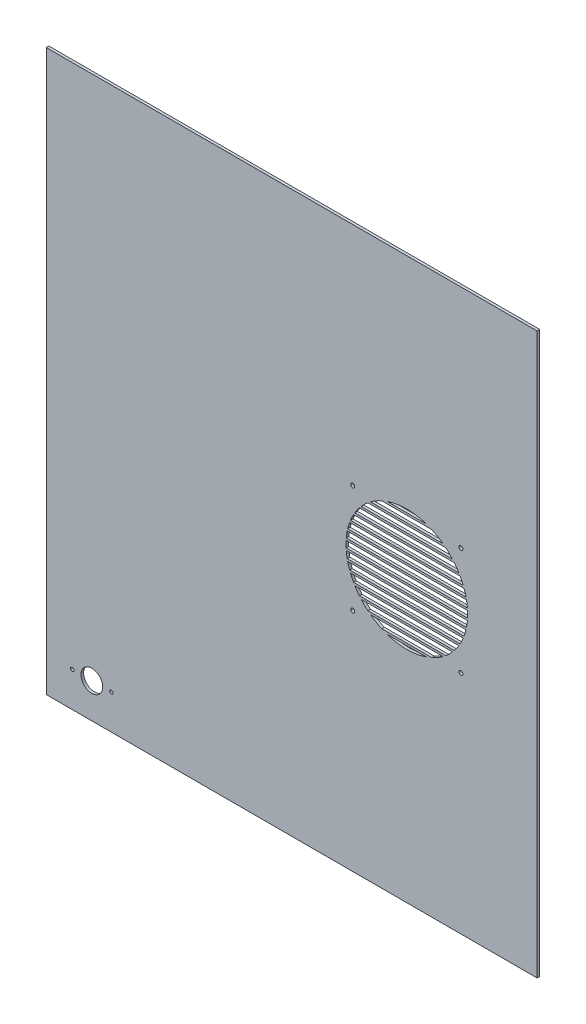
from build123d import *

# Parameters (mm, degrees)
SKICA1_W                = 565
SKICA1_H                = 645
SKICA1_R                = 2
SKICA1_R_2              = 12.5
SKICA1_R_3              = 2.3
P_IDAT_VYSUNUT_M1_DEPTH = 3


with BuildPart() as part:
    # Skica1 → Přidat vysunutím1 (new body)
    with BuildSketch(Plane.XY):
        Rectangle(SKICA1_W, SKICA1_H)
        with BuildLine():
            Line((177.343477787, -53.75), (87.656522213, -53.75))
            ThreePointArc((87.656522213, -53.75), (83.661766134, -50.148049941), (79.955376108, -46.25))
            Line((79.955376108, -46.25), (185.044623892, -46.25))
            ThreePointArc((185.044623892, -46.25), (181.338233866, -50.148049941), (177.343477787, -53.75))
        make_face(mode=Mode.SUBTRACT)
        with BuildLine():
            Line((90.835416719, -56.25), (174.164583281, -56.25))
            ThreePointArc((174.164583281, -56.25), (167.987274157, -60.337827048), (161.412583766, -63.75))
            Line((161.412583766, -63.75), (103.587416234, -63.75))
            ThreePointArc((103.587416234, -63.75), (97.012725843, -60.337827048), (90.835416719, -56.25))
        make_face(mode=Mode.SUBTRACT)
        with Locations((-252.5, -282.5)):
            Circle(SKICA1_R, mode=Mode.SUBTRACT)
        with Locations((-230, -282.5)):
            Circle(SKICA1_R_2, mode=Mode.SUBTRACT)
        with Locations((-207.5, -282.5)):
            Circle(SKICA1_R, mode=Mode.SUBTRACT)
        with BuildLine():
            ThreePointArc((192.382697835, -36.25), (189.885872046, -40.085679357), (187.143732486, -43.75))
            Line((187.143732486, -43.75), (77.856267514, -43.75))
            ThreePointArc((77.856267514, -43.75), (75.114127954, -40.085679357), (72.617302165, -36.25))
            Line((72.617302165, -36.25), (192.382697835, -36.25))
        make_face(mode=Mode.SUBTRACT)
        with BuildLine():
            ThreePointArc((197.391736762, -26.25), (195.720425822, -30.052915979), (193.82648286, -33.75))
            Line((193.82648286, -33.75), (71.17351714, -33.75))
            ThreePointArc((71.17351714, -33.75), (69.279574178, -30.052915979), (67.608263238, -26.25))
            Line((67.608263238, -26.25), (197.391736762, -26.25))
        make_face(mode=Mode.SUBTRACT)
        with BuildLine():
            ThreePointArc((200.587719157, -16.25), (199.572689903, -20.031332187), (198.347835955, -23.75))
            Line((198.347835955, -23.75), (66.652164045, -23.75))
            ThreePointArc((66.652164045, -23.75), (65.427310097, -20.031332187), (64.412280843, -16.25))
            Line((64.412280843, -16.25), (200.587719157, -16.25))
        make_face(mode=Mode.SUBTRACT)
        with BuildLine():
            ThreePointArc((202.220423837, -6.25), (201.779911608, -10.014681604), (201.136269566, -13.75))
            Line((201.136269566, -13.75), (63.863730434, -13.75))
            ThreePointArc((63.863730434, -13.75), (63.220088392, -10.014681604), (62.779576163, -6.25))
            Line((62.779576163, -6.25), (202.220423837, -6.25))
        make_face(mode=Mode.SUBTRACT)
        with BuildLine():
            Line((202.3994814, -3.75), (62.6005186, -3.75))
            ThreePointArc((62.6005186, -3.75), (62.5, 0), (62.6005186, 3.75))
            Line((62.6005186, 3.75), (202.3994814, 3.75))
            ThreePointArc((202.3994814, 3.75), (202.5, 0), (202.3994814, -3.75))
        make_face(mode=Mode.SUBTRACT)
        with BuildLine():
            ThreePointArc((201.136269566, 13.75), (201.779911608, 10.014681604), (202.220423837, 6.25))
            Line((202.220423837, 6.25), (62.779576163, 6.25))
            ThreePointArc((62.779576163, 6.25), (63.220088392, 10.014681604), (63.863730434, 13.75))
            Line((63.863730434, 13.75), (201.136269566, 13.75))
        make_face(mode=Mode.SUBTRACT)
        with BuildLine():
            ThreePointArc((198.347835955, 23.75), (199.572689903, 20.031332187), (200.587719157, 16.25))
            Line((200.587719157, 16.25), (64.412280843, 16.25))
            ThreePointArc((64.412280843, 16.25), (65.427310097, 20.031332187), (66.652164045, 23.75))
            Line((66.652164045, 23.75), (198.347835955, 23.75))
        make_face(mode=Mode.SUBTRACT)
        with BuildLine():
            ThreePointArc((193.82648286, 33.75), (195.720425822, 30.052915979), (197.391736762, 26.25))
            Line((197.391736762, 26.25), (67.608263238, 26.25))
            ThreePointArc((67.608263238, 26.25), (69.279574178, 30.052915979), (71.17351714, 33.75))
            Line((71.17351714, 33.75), (193.82648286, 33.75))
        make_face(mode=Mode.SUBTRACT)
        with BuildLine():
            ThreePointArc((187.143732486, 43.75), (189.885872046, 40.085679357), (192.382697835, 36.25))
            Line((192.382697835, 36.25), (72.617302165, 36.25))
            ThreePointArc((72.617302165, 36.25), (75.114127954, 40.085679357), (77.856267514, 43.75))
            Line((77.856267514, 43.75), (187.143732486, 43.75))
        make_face(mode=Mode.SUBTRACT)
        with BuildLine():
            ThreePointArc((177.343477787, 53.75), (181.338233866, 50.148049941), (185.044623892, 46.25))
            Line((185.044623892, 46.25), (79.955376108, 46.25))
            ThreePointArc((79.955376108, 46.25), (83.661766134, 50.148049941), (87.656522213, 53.75))
            Line((87.656522213, 53.75), (177.343477787, 53.75))
        make_face(mode=Mode.SUBTRACT)
        with BuildLine():
            ThreePointArc((161.412583766, 63.75), (167.987274157, 60.337827048), (174.164583281, 56.25))
            Line((174.164583281, 56.25), (90.835416719, 56.25))
            ThreePointArc((90.835416719, 56.25), (97.012725843, 60.337827048), (103.587416234, 63.75))
            Line((103.587416234, 63.75), (161.412583766, 63.75))
        make_face(mode=Mode.SUBTRACT)
        with Locations((194.75, 62.25)):
            Circle(SKICA1_R_3, mode=Mode.SUBTRACT)
        with BuildLine():
            ThreePointArc((109.89607335, 66.25), (132.5, 70), (155.10392665, 66.25))
            Line((155.10392665, 66.25), (109.89607335, 66.25))
        make_face(mode=Mode.SUBTRACT)
        with Locations((70.25, 62.25)):
            Circle(SKICA1_R_3, mode=Mode.SUBTRACT)
        with Locations((194.75, -62.25)):
            Circle(SKICA1_R_3, mode=Mode.SUBTRACT)
        with Locations((70.25, -62.25)):
            Circle(SKICA1_R_3, mode=Mode.SUBTRACT)
        with BuildLine():
            ThreePointArc((155.10392665, -66.25), (132.5, -70), (109.89607335, -66.25))
            Line((109.89607335, -66.25), (155.10392665, -66.25))
        make_face(mode=Mode.SUBTRACT)
    extrude(amount=P_IDAT_VYSUNUT_M1_DEPTH)


solid = part.part
